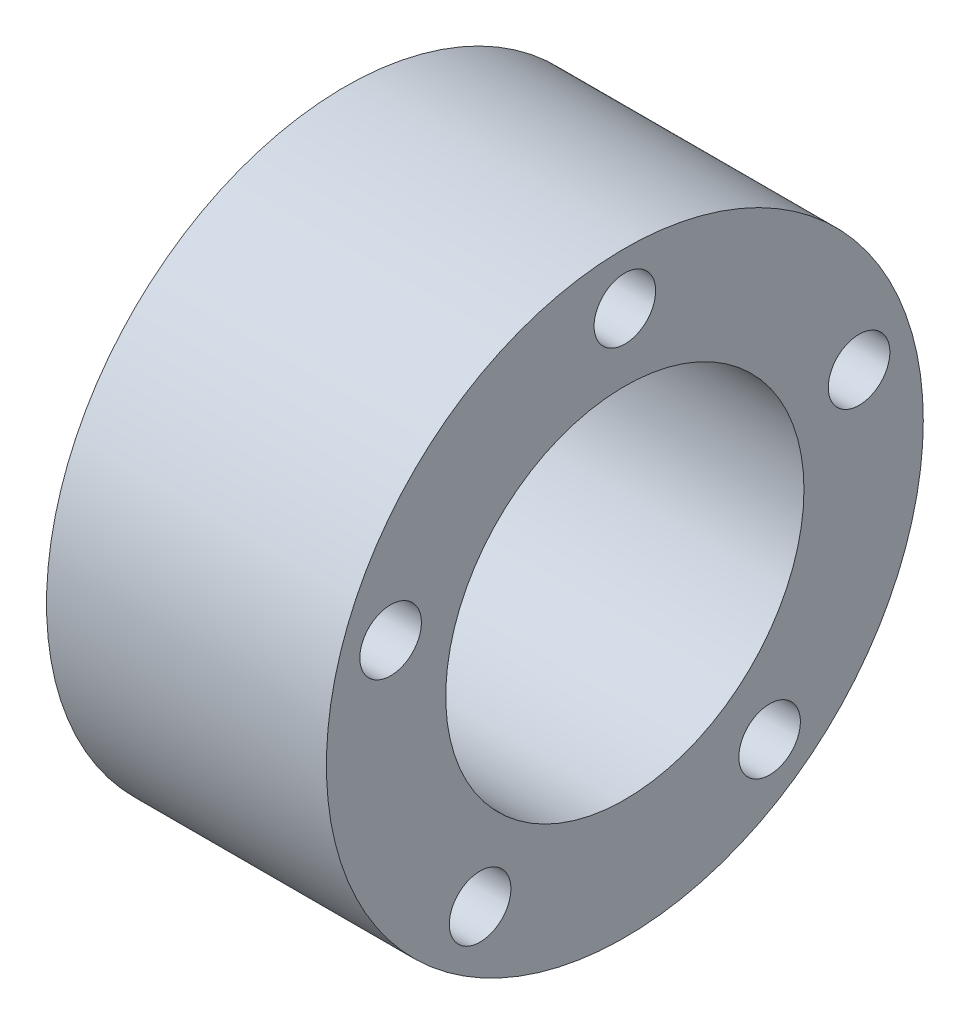
from build123d import *

# Parameters (mm, degrees)
SKETCH1_R           = 13.543461356
SKETCH1_R_2         = 8.128
BOSS_EXTRUDE1_DEPTH = 12.7
SKETCH2_R           = 1.397
CUT_EXTRUDE1_DEPTH  = 13.7


with BuildPart() as part:
    # Sketch1 → Boss-Extrude1 (new body)
    with BuildSketch(Plane(origin=(0, 0, 0), x_dir=(0, 0, -1), z_dir=(1, 0, 0))):
        Circle(SKETCH1_R)
        Circle(SKETCH1_R_2, mode=Mode.SUBTRACT)
    extrude(amount=BOSS_EXTRUDE1_DEPTH)

    # Sketch2 → Cut-Extrude1 (cut, through all)
    with BuildSketch(Plane.ZY):
        with Locations((0, 11.176)):
            Circle(SKETCH2_R)
        with Locations((10.629007626, 3.453573929)):
            Circle(SKETCH2_R)
        with Locations((6.56908798, -9.041573929)):
            Circle(SKETCH2_R)
        with Locations((-6.56908798, -9.041573929)):
            Circle(SKETCH2_R)
        with Locations((-10.629007626, 3.453573929)):
            Circle(SKETCH2_R)
    extrude(amount=-CUT_EXTRUDE1_DEPTH, mode=Mode.SUBTRACT)


solid = part.part
